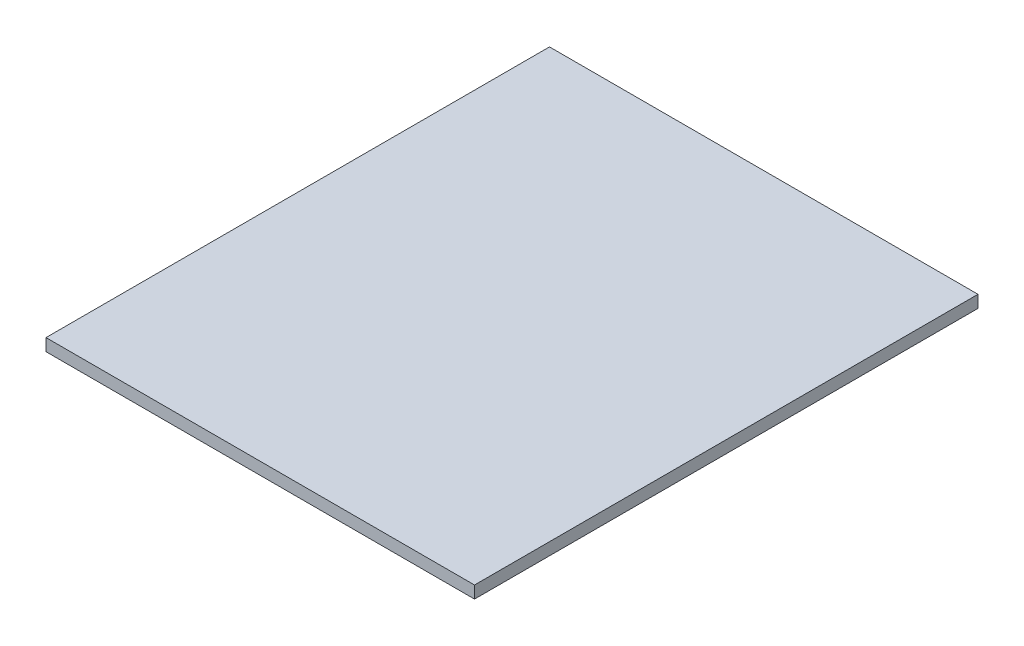
from build123d import *

# Parameters (mm, degrees)
SKETCH1_W      = 560
SKETCH1_H      = 658
EXTRUDE1_DEPTH = 16


with BuildPart() as part:
    # Sketch1 → Extrude1 (new body)
    with BuildSketch(Plane(origin=(0, 0, 0), x_dir=(1, 0, 0), z_dir=(0, 1, 0))):
        with Locations((280, 329)):
            Rectangle(SKETCH1_W, SKETCH1_H)
    extrude(amount=EXTRUDE1_DEPTH)


solid = part.part
